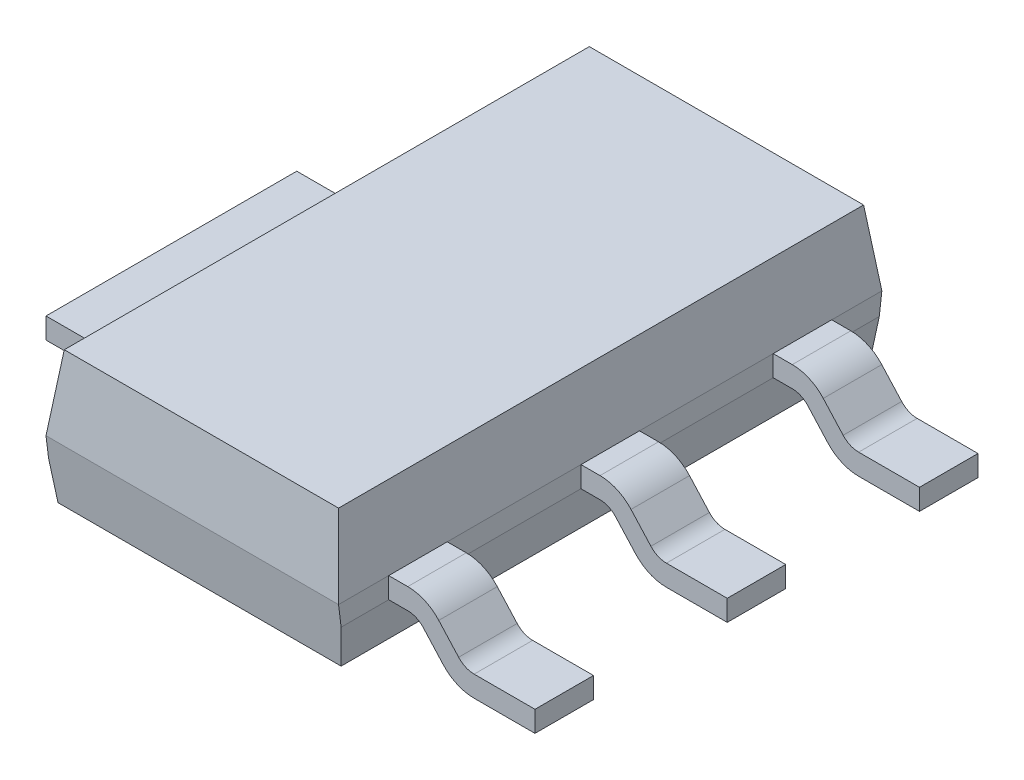
from build123d import *

# Parameters (mm, degrees)
EXTRUDE1_DEPTH     = 3.25
SKETCH2_W          = 1.75
SKETCH2_H          = 1.75
SKETCH2_H_2        = 1.6
SKETCH2_H_3        = 0.6
CUT_EXTRUDE1_DEPTH = 2.65
CUT_EXTRUDE3_DEPTH = 1.75
CUT_EXTRUDE4_DEPTH = 1.75


with BuildPart() as part:
    # Sketch1 → Extrude1 (new body, symmetric)
    with BuildSketch(Plane.XY):
        with BuildLine():
            Line((-1.640721741, 0.89), (1.640721741, 0.89))
            Line((1.640721741, 0.89), (1.75, 0))
            Line((1.75, 0), (1.977970995, 0))
            ThreePointArc((1.977970995, 0), (2.180892756, -0.043028711), (2.34888867, -0.164708965))
            Line((2.34888867, -0.164708965), (2.586570168, -0.427645517))
            ThreePointArc((2.586570168, -0.427645517), (2.670568125, -0.488485644), (2.772029005, -0.51))
            Line((2.772029005, -0.51), (3.5, -0.51))
            Line((3.5, -0.51), (3.5, -0.76))
            Line((3.5, -0.76), (2.772029005, -0.76))
            ThreePointArc((2.772029005, -0.76), (2.569107244, -0.716971289), (2.40111133, -0.595291035))
            Line((2.40111133, -0.595291035), (2.163429832, -0.332354483))
            ThreePointArc((2.163429832, -0.332354483), (2.079431875, -0.271514356), (1.977970995, -0.25))
            Line((1.977970995, -0.25), (1.75, -0.25))
            Line((1.75, -0.25), (1.693519102, -0.71))
            Line((1.693519102, -0.71), (-1.693519102, -0.71))
            Line((-1.693519102, -0.71), (-1.75, -0.25))
            Line((-1.75, -0.25), (-1.977970995, -0.25))
            ThreePointArc((-1.977970995, -0.25), (-2.079431875, -0.271514356), (-2.163429832, -0.332354483))
            Line((-2.163429832, -0.332354483), (-2.40111133, -0.595291035))
            ThreePointArc((-2.40111133, -0.595291035), (-2.569107244, -0.716971289), (-2.772029005, -0.76))
            Line((-2.772029005, -0.76), (-3.5, -0.76))
            Line((-3.5, -0.76), (-3.5, -0.51))
            Line((-3.5, -0.51), (-2.772029005, -0.51))
            ThreePointArc((-2.772029005, -0.51), (-2.670568125, -0.488485644), (-2.586570168, -0.427645517))
            Line((-2.586570168, -0.427645517), (-2.34888867, -0.164708965))
            ThreePointArc((-2.34888867, -0.164708965), (-2.180892756, -0.043028711), (-1.977970995, 0))
            Line((-1.977970995, 0), (-1.75, 0))
            Line((-1.75, 0), (-1.640721741, 0.89))
        make_face()
    extrude(amount=EXTRUDE1_DEPTH, both=True)

    # Sketch2 → Cut-Extrude1 (cut, through all)
    with BuildSketch(Plane(origin=(0, 0.89, 0), x_dir=(1, 0, 0), z_dir=(0, 1, 0))):
        with Locations((-2.625, 2.375)):
            Rectangle(SKETCH2_W, SKETCH2_H)
        with Locations((-2.625, -2.375)):
            Rectangle(SKETCH2_W, SKETCH2_H)
        with Locations((2.625, 1.15)):
            Rectangle(SKETCH2_W, SKETCH2_H_2)
        with Locations((2.625, -1.15)):
            Rectangle(SKETCH2_W, SKETCH2_H_2)
        with Locations((2.625, 2.95)):
            Rectangle(SKETCH2_W, SKETCH2_H_3)
        with Locations((2.625, -2.95)):
            Rectangle(SKETCH2_W, SKETCH2_H_3)
    extrude(amount=-CUT_EXTRUDE1_DEPTH, mode=Mode.SUBTRACT)

    # Sketch3 → Cut-Extrude3 (cut, symmetric)
    with BuildSketch(Plane(origin=(0, 0, 0), x_dir=(0, 0, -1), z_dir=(1, 0, 0))):
        Polygon((3.140721741, 0.89), (3.25, 0), (3.25, 0.89), align=None)
        Polygon((-3.25, 0), (-3.25, 0.89), (-3.140721741, 0.89), align=None)
    extrude(amount=CUT_EXTRUDE3_DEPTH, both=True, mode=Mode.SUBTRACT)

    # Sketch4 → Cut-Extrude4 (cut, symmetric)
    with BuildSketch(Plane(origin=(0, 0, 0), x_dir=(0, 0, -1), z_dir=(1, 0, 0))):
        Polygon((3.162822962, -0.71), (3.25, -0.71), (3.25, 0), align=None)
        Polygon((-3.25, 0), (-3.162822962, -0.71), (-3.25, -0.71), align=None)
    extrude(amount=CUT_EXTRUDE4_DEPTH, both=True, mode=Mode.SUBTRACT)


solid = part.part
